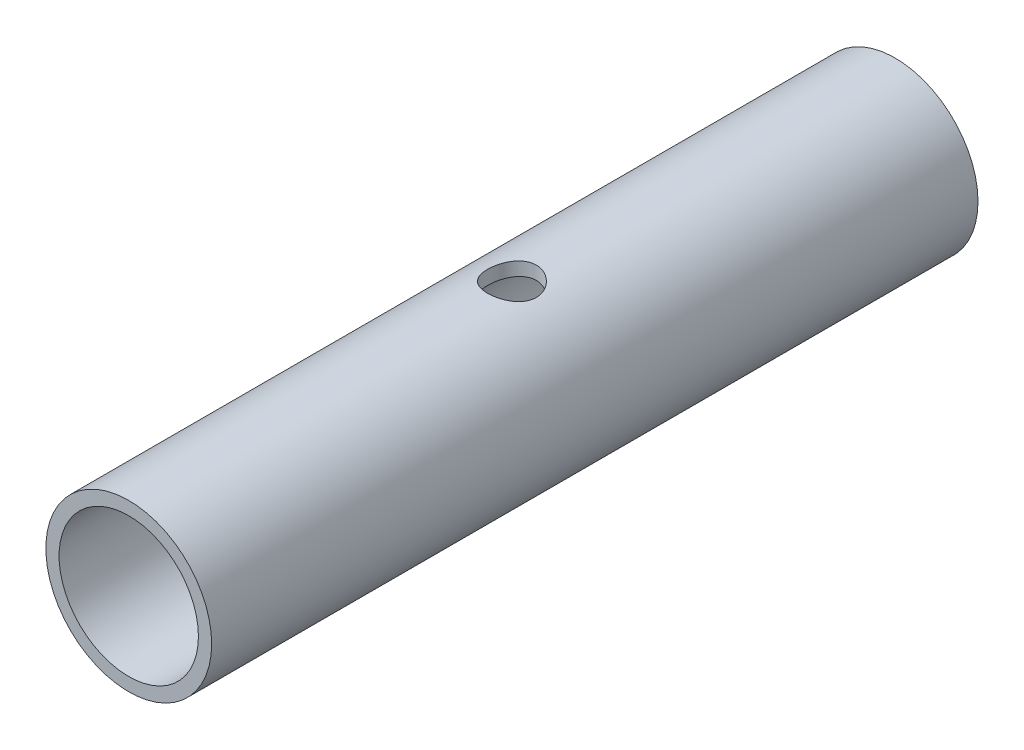
from build123d import *

# Parameters (mm, degrees)
SKETCH1_R           = 30.226
SKETCH1_R_2         = 25.4
BOSS_EXTRUDE1_DEPTH = 139.7
CUT_EXTRUDE1_REACH  = 32.226
SKETCH2_R           = 8.89


with BuildPart() as part:
    # Sketch1 → Boss-Extrude1 (new body, symmetric)
    with BuildSketch(Plane.XY):
        Circle(SKETCH1_R)
        Circle(SKETCH1_R_2, mode=Mode.SUBTRACT)
    extrude(amount=BOSS_EXTRUDE1_DEPTH, both=True)

    # Sketch2 → Cut-Extrude1 (cut, up to next)
    with BuildSketch(Plane(origin=(0, 0, 0), x_dir=(1, 0, 0), z_dir=(0, 1, 0)), mode=Mode.PRIVATE) as cut_extrude1_sk1:
        Circle(SKETCH2_R)
    cut_extrude1_tool1 = extrude(cut_extrude1_sk1.sketch, amount=CUT_EXTRUDE1_REACH, mode=Mode.PRIVATE) & part.part
    add(cut_extrude1_tool1.solids().sort_by_distance((0, 0, 0))[0], mode=Mode.SUBTRACT)


solid = part.part
